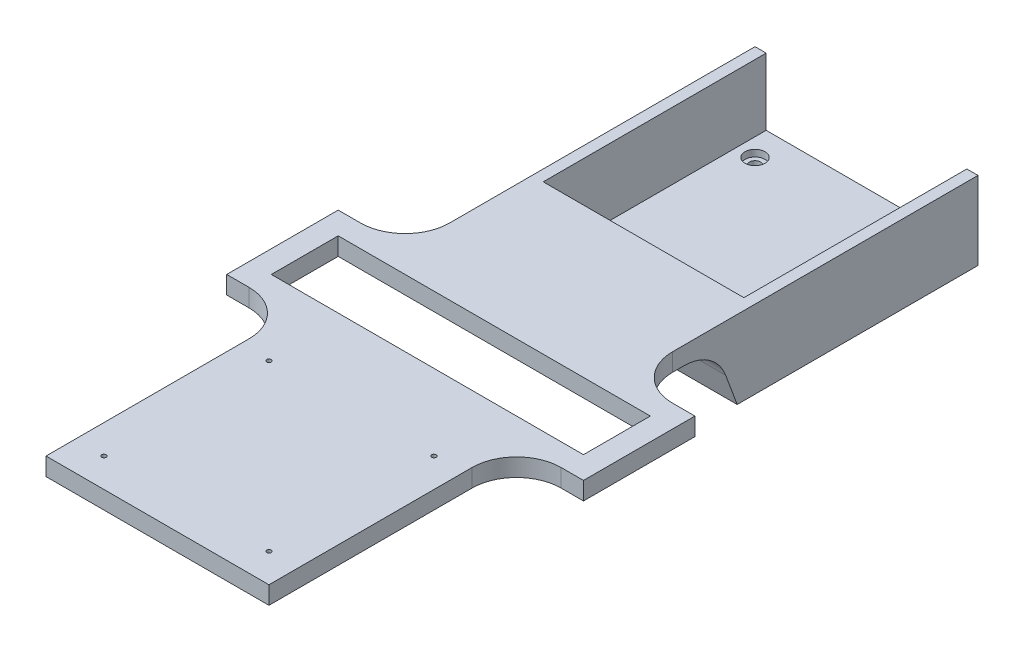
from build123d import *

# Parameters (mm, degrees)
SKETCH1_W           = 100
SKETCH1_H           = 100
SKETCH1_R           = 2.5
BOSS_EXTRUDE1_DEPTH = 5
CUT_EXTRUDE1_START  = -5
SKETCH6_R           = 4.5
CUT_EXTRUDE1_DEPTH  = 3
SKETCH8_W           = 8
SKETCH8_H           = 35
BOSS_EXTRUDE2_DEPTH = 100
SKETCH9_W           = 100
SKETCH9_H           = 8
BOSS_EXTRUDE3_DEPTH = 210
SKETCH10_W          = 160
SKETCH10_H          = 50
BOSS_EXTRUDE4_DEPTH = 8
SKETCH11_W          = 140
SKETCH11_H          = 30
CUT_EXTRUDE2_DEPTH  = 8
SKETCH13_R          = 1
CUT_EXTRUDE3_DEPTH  = 8
FILLET1_R           = 20
BOSS_EXTRUDE5_DEPTH = 100
FILLET3_R           = 20
SKETCH15_W          = 5
SKETCH15_H          = 100
BOSS_EXTRUDE6_DEPTH = 30


with BuildPart() as part:
    # Sketch1 → Boss-Extrude1 (new body)
    with BuildSketch(Plane(origin=(0, 0, 0), x_dir=(1, 0, 0), z_dir=(0, 1, 0))):
        Rectangle(SKETCH1_W, SKETCH1_H)
        with Locations((-36.95, 36.95)):
            Circle(SKETCH1_R, mode=Mode.SUBTRACT)
        with Locations((36.95, 36.95)):
            Circle(SKETCH1_R, mode=Mode.SUBTRACT)
        with Locations((36.95, -36.95)):
            Circle(SKETCH1_R, mode=Mode.SUBTRACT)
        with Locations((-36.95, -36.95)):
            Circle(SKETCH1_R, mode=Mode.SUBTRACT)
    extrude(amount=BOSS_EXTRUDE1_DEPTH)

    # Sketch6 → Cut-Extrude1 (cut)
    with BuildSketch(Plane.XZ.offset(CUT_EXTRUDE1_START)):
        with Locations((-36.95, 36.95)):
            Circle(SKETCH6_R)
        with Locations((36.95, 36.95)):
            Circle(SKETCH6_R)
        with Locations((36.95, -36.95)):
            Circle(SKETCH6_R)
        with Locations((-36.95, -36.95)):
            Circle(SKETCH6_R)
    extrude(amount=CUT_EXTRUDE1_DEPTH, mode=Mode.SUBTRACT)

    # Sketch8 → Boss-Extrude2 (add, through all)
    with BuildSketch(Plane.ZY.offset(50)):
        with Locations((54, 17.5)):
            Rectangle(SKETCH8_W, SKETCH8_H)
    extrude(amount=-BOSS_EXTRUDE2_DEPTH)

    # Sketch9 → Boss-Extrude3 (add)
    with BuildSketch(Plane.XY.offset(58)):
        with Locations((0, 31)):
            Rectangle(SKETCH9_W, SKETCH9_H)
    extrude(amount=BOSS_EXTRUDE3_DEPTH)

    # Sketch10 → Boss-Extrude4 (add)
    with BuildSketch(Plane(origin=(0, 35, 0), x_dir=(1, 0, 0), z_dir=(0, 1, 0))):
        with Locations((0, -131.95)):
            Rectangle(SKETCH10_W, SKETCH10_H)
    extrude(amount=-BOSS_EXTRUDE4_DEPTH)

    # Sketch11 → Cut-Extrude2 (cut)
    with BuildSketch(Plane(origin=(0, 35, 0), x_dir=(1, 0, 0), z_dir=(0, 1, 0))):
        with Locations((0, -131.95)):
            Rectangle(SKETCH11_W, SKETCH11_H)
    extrude(amount=-CUT_EXTRUDE2_DEPTH, mode=Mode.SUBTRACT)

    # Sketch13 → Cut-Extrude3 (cut)
    with BuildSketch(Plane(origin=(0, 35, 0), x_dir=(1, 0, 0), z_dir=(0, 1, 0))):
        with Locations((-37, -181)):
            Circle(SKETCH13_R)
        with Locations((37, -181)):
            Circle(SKETCH13_R)
        with Locations((37, -255)):
            Circle(SKETCH13_R)
        with Locations((-37, -255)):
            Circle(SKETCH13_R)
    extrude(amount=-CUT_EXTRUDE3_DEPTH, mode=Mode.SUBTRACT)

    # Fillet1
    fillet1_edges = [part.edges().sort_by_distance(p)[0] for p in [
        (50, 31, 156.95),
        (-50, 31, 156.95),
        (50, 31, 106.95),
        (-50, 31, 106.95),
    ]]
    fillet(fillet1_edges, radius=FILLET1_R)

    # Sketch14 → Boss-Extrude5 (add)
    with BuildSketch(Plane.ZY.offset(50)):
        Polygon((58, 0), (58, 27), (68, 27), align=None)
    extrude(amount=-BOSS_EXTRUDE5_DEPTH)

    # Fillet3
    fillet3_edges = [part.edges().sort_by_distance(p)[0] for p in [
        (0, 27, 68),
    ]]
    fillet(fillet3_edges, radius=FILLET3_R)

    # Sketch15 → Boss-Extrude6 (add)
    with BuildSketch(Plane(origin=(0, 5, 0), x_dir=(1, 0, 0), z_dir=(0, 1, 0))):
        with Locations((-47.5, 0)):
            Rectangle(SKETCH15_W, SKETCH15_H)
        with Locations((47.5, 0)):
            Rectangle(SKETCH15_W, SKETCH15_H)
    extrude(amount=BOSS_EXTRUDE6_DEPTH)


solid = part.part
